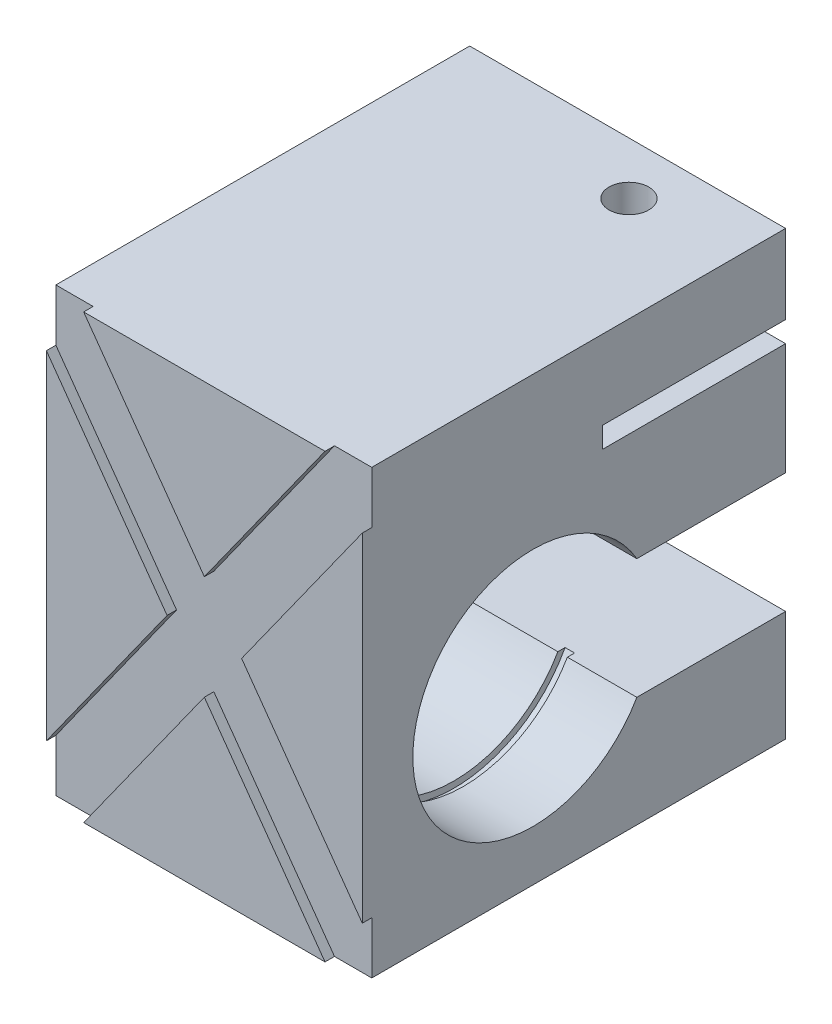
from build123d import *

# Parameters (mm, degrees)
SKETCH1_W                 = 50
SKETCH1_H                 = 70
BOSS_EXTRUDE1_DEPTH       = 33.5
CUT_EXTRUDE2_DEPTH        = 1.5
SKETCH3_W                 = 29
SKETCH3_H                 = 3.3
CUT_EXTRUDE3_DEPTH        = 51
CUT_EXTRUDE4_DEPTH        = 51
F_6_0MM_DOWEL_HOLE2_D     = 6.3
F_6_0MM_DOWEL_HOLE2_DEPTH = 12.5
CUT_EXTRUDE6_DEPTH        = 1.5


with BuildPart() as part:
    # Sketch1 → Boss-Extrude1 (new body, symmetric)
    with BuildSketch(Plane.XY):
        with Locations((25, 35)):
            Rectangle(SKETCH1_W, SKETCH1_H)
    extrude(amount=BOSS_EXTRUDE1_DEPTH, both=True)

    # Sketch2 → Cut-Extrude2 (cut)
    with BuildSketch(Plane.XY.offset(33.5)):
        Polygon((19.101262674, 35), (25, 43.258232256), (5.898737326, 70), (0, 70), (0, 61.741767744), align=None)
        Polygon((50, 0), (50, 8.258232256), (30.898737326, 35), (25, 26.741767744), (44.101262674, 0), align=None)
        Polygon((25, 43.258232256), (30.898737326, 35), (50, 61.741767744), (50, 70), (44.101262674, 70), align=None)
        Polygon((5.898737326, 0), (25, 26.741767744), (19.101262674, 35), (0, 8.258232256), (0, 0), align=None)
        Polygon((25, 26.741767744), (30.898737326, 35), (25, 43.258232256), (19.101262674, 35), align=None)
    extrude(amount=-CUT_EXTRUDE2_DEPTH, mode=Mode.SUBTRACT)

    # Sketch3 → Cut-Extrude3 (cut, through all)
    with BuildSketch(Plane(origin=(50, 0, 0), x_dir=(0, 0, -1), z_dir=(1, 0, 0))):
        with Locations((19, 55.85)):
            Rectangle(SKETCH3_W, SKETCH3_H)
    extrude(amount=-CUT_EXTRUDE3_DEPTH, mode=Mode.SUBTRACT)

    # Sketch4 → Cut-Extrude4 (cut, through all)
    with BuildSketch(Plane(origin=(50, 0, 0), x_dir=(0, 0, -1), z_dir=(1, 0, 0))):
        with BuildLine():
            Line((33.5, 36.5), (9.954482672, 36.5))
            ThreePointArc((9.954482672, 36.5), (-25.5, 27), (9.954482672, 17.5))
            Line((9.954482672, 17.5), (33.5, 17.5))
            Line((33.5, 17.5), (33.5, 36.5))
        make_face()
    extrude(amount=-CUT_EXTRUDE4_DEPTH, mode=Mode.SUBTRACT)

    # Ø6.0mm Dowel Hole2
    with Locations(Plane(origin=(0, 70, 0), x_dir=(1, 0, 0), z_dir=(0, 1, 0))):
        with Locations((33.5, 25.2)):
            Hole(F_6_0MM_DOWEL_HOLE2_D / 2, depth=F_6_0MM_DOWEL_HOLE2_DEPTH)

    # Sketch15 → Cut-Extrude6 (cut)
    with BuildSketch(Plane(origin=(37.5, 0, 0), x_dir=(0, 0, -1), z_dir=(1, 0, 0))):
        with BuildLine():
            Line((9.954482672, 36.5), (11.099715907, 36.5))
            ThreePointArc((11.099715907, 36.5), (-26.5, 27), (11.099715907, 17.5))
            Line((11.099715907, 17.5), (9.954482672, 17.5))
            ThreePointArc((9.954482672, 17.5), (-25.5, 27), (9.954482672, 36.5))
        make_face()
    cut_extrude6 = extrude(amount=CUT_EXTRUDE6_DEPTH, mode=Mode.SUBTRACT)

    # Mirror2: Cut-Extrude6 across plane
    add(cut_extrude6.mirror(Plane(origin=(25, 0, 0), x_dir=(0, 0, 1), z_dir=(1, 0, 0))), mode=Mode.SUBTRACT)


solid = part.part
